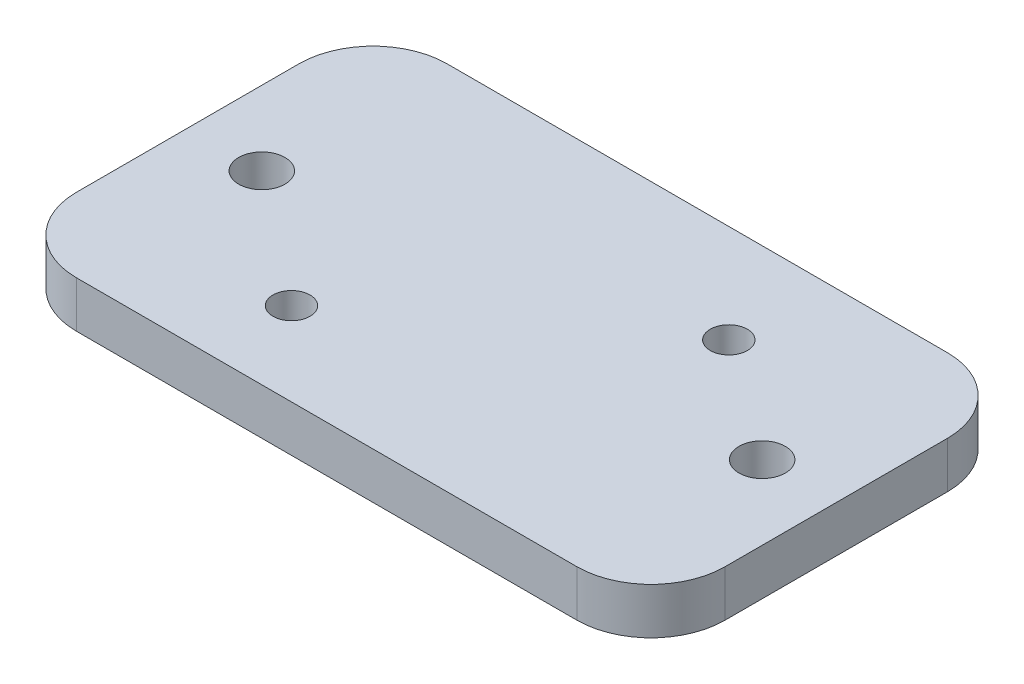
from build123d import *

# Parameters (mm, degrees)
BOSS_EXTRUDE1_DEPTH = 3.175
CUT_EXTRUDE1_REACH  = 5.175
SKETCH2_R           = 1.5875
CUT_EXTRUDE2_REACH  = 5.175
SKETCH3_R           = 1.27
CUT_EXTRUDE3_DEPTH  = 1.5875


with BuildPart() as part:
    # Sketch1 → Boss-Extrude1 (new body)
    with BuildSketch(Plane(origin=(0, 0, 0), x_dir=(1, 0, 0), z_dir=(0, 1, 0))):
        with BuildLine():
            Line((5.08, 0), (39.37, 0))
            ThreePointArc((39.37, 0), (42.962102448, 1.487897552), (44.45, 5.08))
            Line((44.45, 5.08), (44.45, 20.32))
            ThreePointArc((44.45, 20.32), (42.962102448, 23.912102448), (39.37, 25.4))
            Line((39.37, 25.4), (5.08, 25.4))
            ThreePointArc((5.08, 25.4), (1.487897552, 23.912102448), (0, 20.32))
            Line((0, 20.32), (0, 5.08))
            ThreePointArc((0, 5.08), (1.487897552, 1.487897552), (5.08, 0))
        make_face()
    extrude(amount=BOSS_EXTRUDE1_DEPTH)

    # Sketch2 → Cut-Extrude1 (cut, up to next)
    with BuildSketch(Plane.XZ, mode=Mode.PRIVATE) as cut_extrude1_sk1:
        with Locations((5.08, -12.7)):
            Circle(SKETCH2_R)
    cut_extrude1_tool1 = extrude(cut_extrude1_sk1.sketch, amount=-CUT_EXTRUDE1_REACH, mode=Mode.PRIVATE) & part.part
    add(cut_extrude1_tool1.solids().sort_by_distance((5.08, 0, -12.7))[0], mode=Mode.SUBTRACT)
    # Sketch2 → Cut-Extrude1 (cut, up to next)
    with BuildSketch(Plane.XZ, mode=Mode.PRIVATE) as cut_extrude1_sk2:
        with Locations((39.37, -12.7)):
            Circle(SKETCH2_R)
    cut_extrude1_tool2 = extrude(cut_extrude1_sk2.sketch, amount=-CUT_EXTRUDE1_REACH, mode=Mode.PRIVATE) & part.part
    add(cut_extrude1_tool2.solids().sort_by_distance((39.37, 0, -12.7))[0], mode=Mode.SUBTRACT)

    # Sketch3 → Cut-Extrude2 (cut, up to next)
    with BuildSketch(Plane.XZ, mode=Mode.PRIVATE) as cut_extrude2_sk1:
        with Locations((14.097, -5.715)):
            Circle(SKETCH3_R)
    cut_extrude2_tool1 = extrude(cut_extrude2_sk1.sketch, amount=-CUT_EXTRUDE2_REACH, mode=Mode.PRIVATE) & part.part
    add(cut_extrude2_tool1.solids().sort_by_distance((14.097, 0, -5.715))[0], mode=Mode.SUBTRACT)
    # Sketch3 → Cut-Extrude2 (cut, up to next)
    with BuildSketch(Plane.XZ, mode=Mode.PRIVATE) as cut_extrude2_sk2:
        with Locations((31.115, -18.669)):
            Circle(SKETCH3_R)
    cut_extrude2_tool2 = extrude(cut_extrude2_sk2.sketch, amount=-CUT_EXTRUDE2_REACH, mode=Mode.PRIVATE) & part.part
    add(cut_extrude2_tool2.solids().sort_by_distance((31.115, 0, -18.669))[0], mode=Mode.SUBTRACT)

    # Sketch4 → Cut-Extrude3 (cut)
    with BuildSketch(Plane.XZ):
        with BuildLine():
            Line((13.34350835, -19.894123354), (29.031244989, -19.894123354))
            ThreePointArc((29.031244989, -19.894123354), (30.409467748, -21.272346113), (29.031244989, -22.650568872))
            Line((29.031244989, -22.650568872), (13.34350835, -22.650568872))
            ThreePointArc((13.34350835, -22.650568872), (11.965285591, -21.272346113), (13.34350835, -19.894123354))
        make_face()
    extrude(amount=-CUT_EXTRUDE3_DEPTH, mode=Mode.SUBTRACT)


solid = part.part
